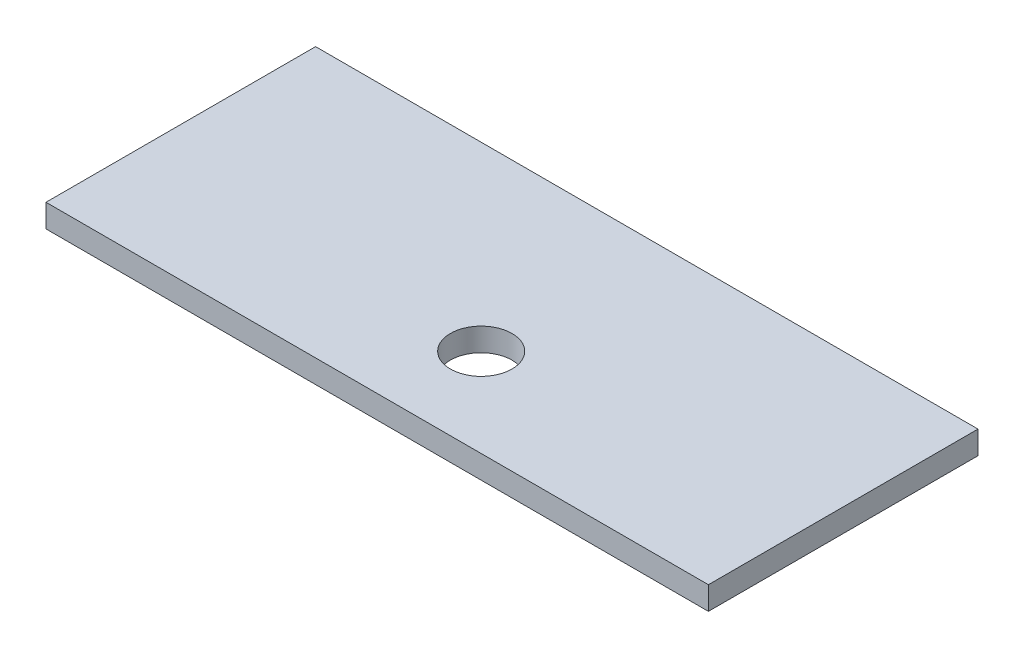
from build123d import *

# Parameters (mm, degrees)
SKETCH_1_W      = 43
SKETCH_1_H      = 17.5
SKETCH_1_R      = 2
EXTRUDE_1_DEPTH = 1.5


with BuildPart() as part:
    # Эскиз1 → Бобышка-Вытянуть1 (new body)
    with BuildSketch(Plane(origin=(0, 0, 0), x_dir=(1, 0, 0), z_dir=(0, 1, 0))):
        with Locations((21.5, 8.75)):
            Rectangle(SKETCH_1_W, SKETCH_1_H)
        with Locations((22.5, 5.75)):
            Circle(SKETCH_1_R, mode=Mode.SUBTRACT)
    extrude(amount=EXTRUDE_1_DEPTH)


solid = part.part
